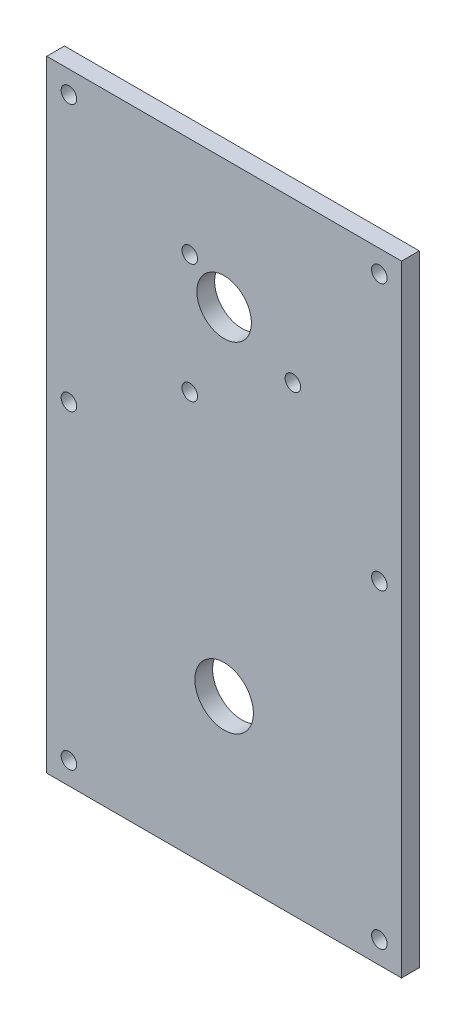
from build123d import *

# Parameters (mm, degrees)
SKETCH_1_R      = 1.75
EXTRUDE_1_DEPTH = 4


with BuildPart() as part:
    # ｽｹｯﾁ1 → ﾎﾞｽ - 押し出し1 (new body)
    with BuildSketch(Plane.XY):
        Polygon((0, 0), (40, 0), (80, 0), (80, 140), (0, 140), align=None)
        with Locations((5, 135)):
            Circle(SKETCH_1_R, mode=Mode.SUBTRACT)
        with Locations((5, 5)):
            Circle(SKETCH_1_R, mode=Mode.SUBTRACT)
        with BuildLine():
            ThreePointArc((40, 41.6), (46.6, 35), (40, 28.4))
            ThreePointArc((40, 28.4), (33.4, 35), (40, 41.6))
        make_face(mode=Mode.SUBTRACT)
        with Locations((75, 5)):
            Circle(SKETCH_1_R, mode=Mode.SUBTRACT)
        with Locations((5, 75)):
            Circle(SKETCH_1_R, mode=Mode.SUBTRACT)
        with Locations((32.25, 90.576606241)):
            Circle(SKETCH_1_R, mode=Mode.SUBTRACT)
        with Locations((32.25, 117.423393759)):
            Circle(SKETCH_1_R, mode=Mode.SUBTRACT)
        with Locations((75, 75)):
            Circle(SKETCH_1_R, mode=Mode.SUBTRACT)
        with BuildLine():
            ThreePointArc((34.440448115, 113.629426332), (45.326056233, 114.075), (39.497374059, 104.870573668))
            ThreePointArc((39.497374059, 104.870573668), (34.673943767, 107.925), (34.440448115, 113.629426332))
        make_face(mode=Mode.SUBTRACT)
        with Locations((55.5, 104)):
            Circle(SKETCH_1_R, mode=Mode.SUBTRACT)
        with Locations((75, 135)):
            Circle(SKETCH_1_R, mode=Mode.SUBTRACT)
    extrude(amount=EXTRUDE_1_DEPTH)


solid = part.part
